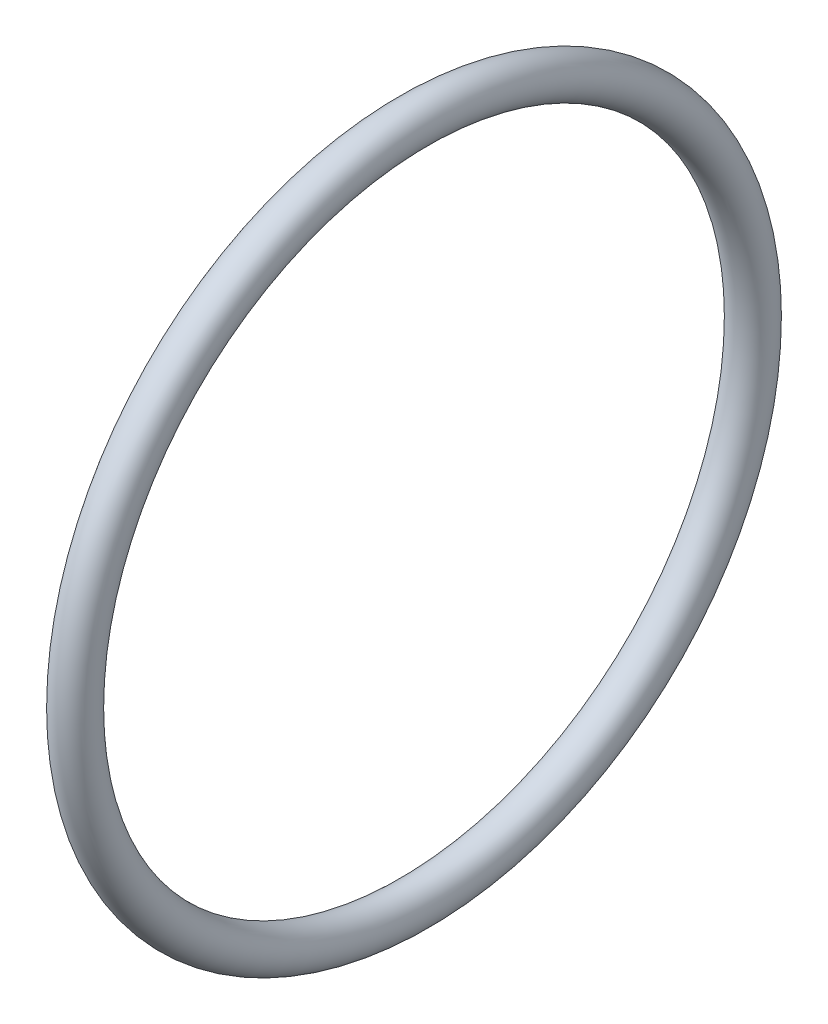
from build123d import *

# Parameters (mm, degrees)
SKETCH3_R = 0.950000005


with BuildPart() as part:
    # Sketch3 → Revolve1 (revolve)
    with BuildSketch(Plane.XY):
        with Locations((21.989799937, 15.949999977)):
            Circle(SKETCH3_R)
    revolve(axis=Axis((0, 0, 0), (1, 0, 0)))


solid = part.part
